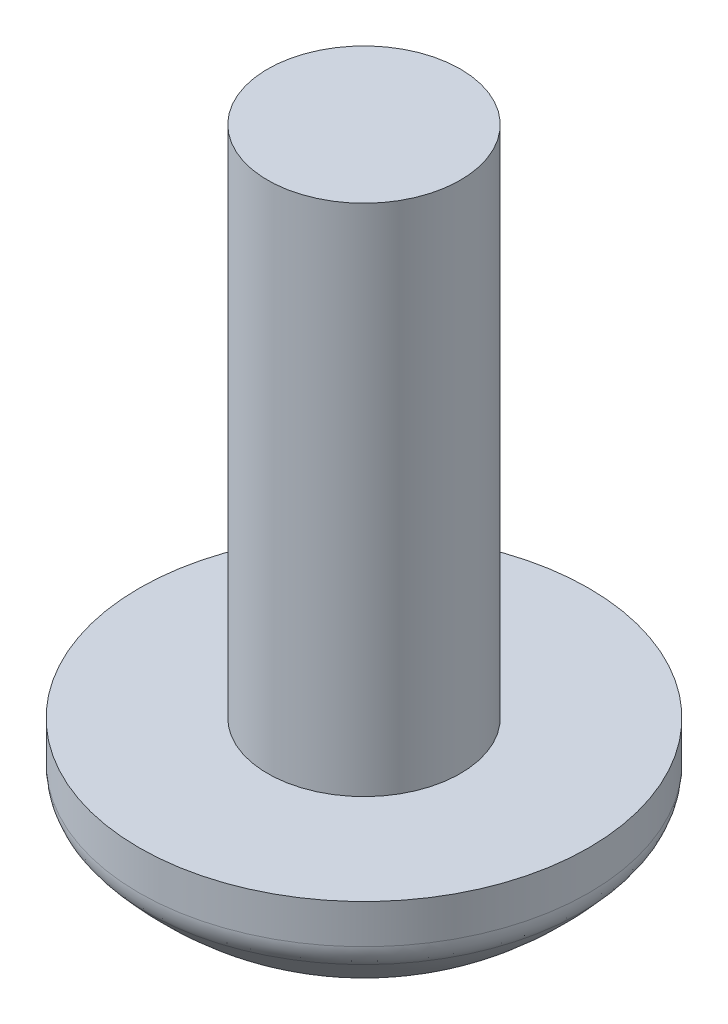
from build123d import *

# Parameters (mm, degrees)
FILLET_1_R          = 0.5
CUT_EXTRUDE_1_DEPTH = 1.5


with BuildPart() as part:
    # 草图2 → 旋转1 (revolve)
    with BuildSketch(Plane(origin=(0, 0, 0), x_dir=(0, 0, -1), z_dir=(1, 0, 0))):
        with BuildLine():
            Line((1.817800027, -0.459726703), (-0.182199973, -0.459726703))
            Line((-0.182199973, -0.459726703), (-0.182199973, 7.540273297))
            Line((-0.182199973, 7.540273297), (-1.682199973, 7.540273297))
            Line((-1.682199973, 7.540273297), (-1.682199973, -0.459726703))
            Line((-1.682199973, -0.459726703), (-1.682199973, -2.959726703))
            add(Edge.make_bspline(
                [(1.817800027, -1.252007585), (1.177768259, -2.02578844), (0.30662425, -2.840564308), (-1.682199973, -2.959726703)],
                knots=[0, 0, 0, 0, 1, 1, 1, 1], degree=3))
            Line((1.817800027, -1.252007585), (1.817800027, -0.459726703))
        make_face()
    revolve(axis=Axis((0, -0.459726703, 1.682199973), (0, 1, 0)))

    # 圆角1
    fillet_1_edges = [part.edges().sort_by_distance(p)[0] for p in [
        (0, -1.252007585, 5.182199973),
    ]]
    fillet(fillet_1_edges, radius=FILLET_1_R)

    # 草图3 → 切除-拉伸1 (cut)
    with BuildSketch(Plane(origin=(0, -2.959726703, 0), x_dir=(-1, 0, 0), z_dir=(0, -1, 0))):
        Polygon((-0.470758808, -1.182199973), (-2.75, -1.182199973), (-2.75, -2.182199973), (-0.470758808, -2.182199973), (-0.470758808, -4.426883393), (0.529241192, -4.426883393), (0.529241192, -2.182199973), (2.75, -2.182199973), (2.75, -1.182199973), (0.529241192, -1.182199973), (0.529241192, 1.073116607), (-0.470758808, 1.073116607), align=None)
    extrude(amount=-CUT_EXTRUDE_1_DEPTH, mode=Mode.SUBTRACT)


solid = part.part
